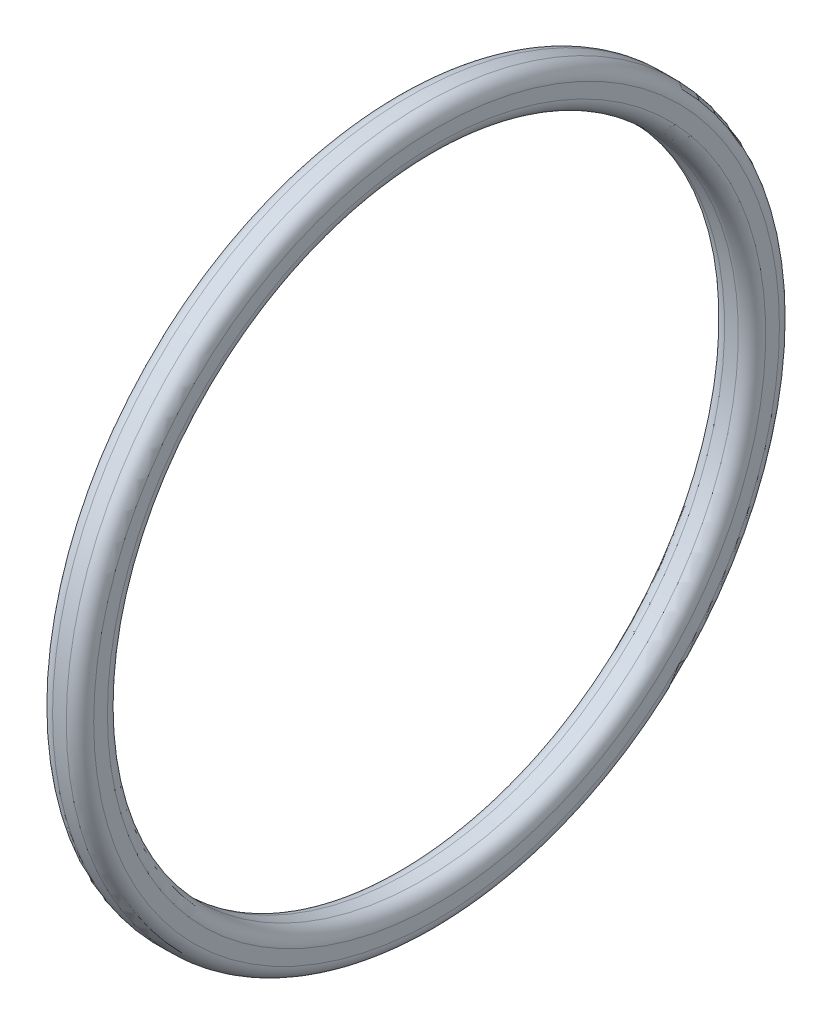
from build123d import *


with BuildPart() as part:
    # Esquisse1 → Base-Révolution (revolve)
    with BuildSketch(Plane.XY, mode=Mode.PRIVATE) as base_r_volution_sk:
        with BuildLine():
            Line((0.5, 11.5), (1, 11.5))
            ThreePointArc((1, 11.5), (1.353553391, 11.646446609), (1.5, 12))
            Line((1.5, 12), (1.5, 12.5))
            ThreePointArc((1.5, 12.5), (1.353553391, 12.853553391), (1, 13))
            Line((1, 13), (0.5, 13))
            ThreePointArc((0.5, 13), (0.146446609, 12.853553391), (0, 12.5))
            Line((0, 12.5), (0, 12))
            ThreePointArc((0, 12), (0.146446609, 11.646446609), (0.5, 11.5))
        make_face()
    revolve(base_r_volution_sk.sketch.rotate(Axis((-12.332036424, 0, 0), (1, 0, 0)), 90), axis=Axis((-12.332036424, 0, 0), (1, 0, 0)))  # turned: the seam where the file's is


solid = part.part
